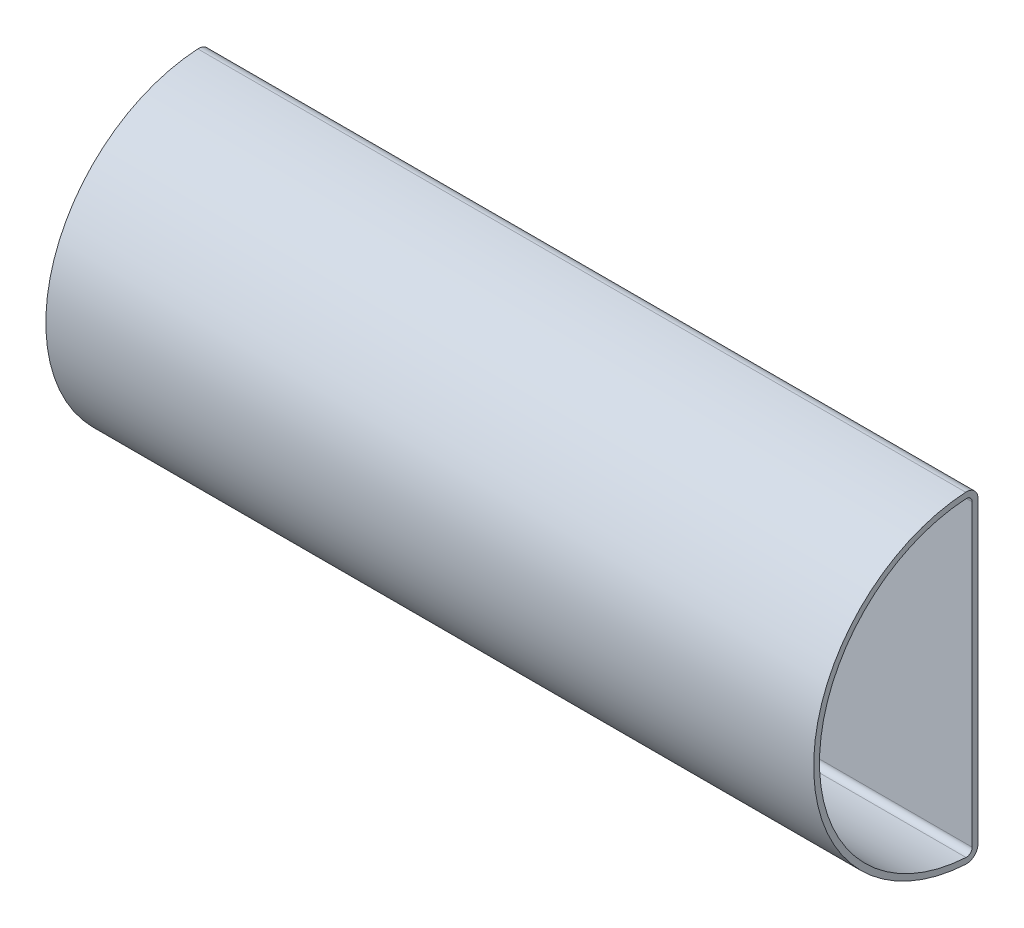
from build123d import *

# Parameters (mm, degrees)
BOSS_EXTRUDE1_DEPTH = 264


with BuildPart() as part:
    # Sketch1 → Boss-Extrude1 (new body)
    with BuildSketch(Plane(origin=(0, 0, 0), x_dir=(0, 0, -1), z_dir=(1, 0, 0))):
        with BuildLine():
            Line((-7.783565859, 51.412547107), (-7.783565859, -51.412547107))
            ThreePointArc((-7.783565859, -51.412547107), (-9.038756106, -54.322189596), (-12.016575568, -55.405754649))
            ThreePointArc((-12.016575568, -55.405754649), (-64.283565859, 0), (-12.016575568, 55.405754649))
            ThreePointArc((-12.016575568, 55.405754649), (-9.038756106, 54.322189596), (-7.783565859, 51.412547107))
        make_face()
        with BuildLine():
            Line((-9.783565859, 51.412547107), (-9.783565859, -51.412547107))
            ThreePointArc((-9.783565859, -51.412547107), (-10.411160983, -52.867368352), (-11.900070714, -53.409150878))
            ThreePointArc((-11.900070714, -53.409150878), (-62.283565859, 0), (-11.900070714, 53.409150878))
            ThreePointArc((-11.900070714, 53.409150878), (-10.411160983, 52.867368352), (-9.783565859, 51.412547107))
        make_face(mode=Mode.SUBTRACT)
    extrude(amount=BOSS_EXTRUDE1_DEPTH)


solid = part.part
